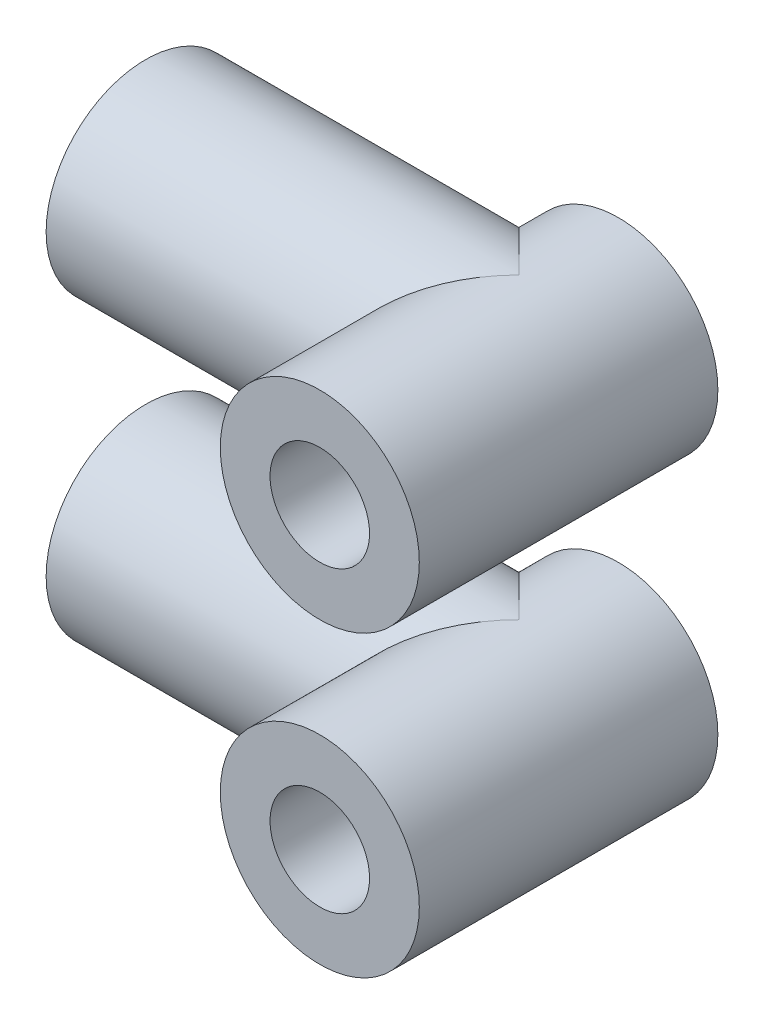
from build123d import *

# Parameters (mm, degrees)
SKETCH1_R           = 4
SKETCH1_R_2         = 2
BOSS_EXTRUDE1_DEPTH = 12
SKETCH2_R           = 4
SKETCH2_R_2         = 2
BOSS_EXTRUDE2_DEPTH = 15
SKETCH3_R           = 2
CUT_EXTRUDE1_DEPTH  = 13.0000001
CUT_EXTRUDE2_REACH  = 21
SKETCH4_R           = 2


with BuildPart() as part:
    # Sketch1 → Boss-Extrude1 (new body)
    with BuildSketch(Plane.XY):
        Circle(SKETCH1_R)
        Circle(SKETCH1_R_2, mode=Mode.SUBTRACT)
    extrude(amount=BOSS_EXTRUDE1_DEPTH)

    # Sketch2 → Boss-Extrude2 (add)
    with BuildSketch(Plane(origin=(0, 0, 0), x_dir=(0, 0, -1), z_dir=(1, 0, 0))):
        with Locations((-4, 0)):
            Circle(SKETCH2_R)
        with Locations((-4, 0)):
            Circle(SKETCH2_R_2, mode=Mode.SUBTRACT)
    extrude(amount=-BOSS_EXTRUDE2_DEPTH)

    # Sketch3 → Cut-Extrude1 (cut, through all)
    with BuildSketch(Plane(origin=(0, 0, 0), x_dir=(-1, 0, 0), z_dir=(0, 0, -1))):
        Circle(SKETCH3_R)
    extrude(amount=-CUT_EXTRUDE1_DEPTH, mode=Mode.SUBTRACT)

    # Sketch4 → Cut-Extrude2 (cut, up to next)
    with BuildSketch(Plane.ZY.offset(15), mode=Mode.PRIVATE) as cut_extrude2_sk1:
        with Locations((4, 0)):
            Circle(SKETCH4_R)
    cut_extrude2_tool1 = extrude(cut_extrude2_sk1.sketch, amount=-CUT_EXTRUDE2_REACH, mode=Mode.PRIVATE) & part.part
    add(cut_extrude2_tool1.solids().sort_by_distance((-15, 0, 4))[0], mode=Mode.SUBTRACT)


with BuildPart() as body_2:
    # Mirror1: mirrored copy
    add(part.part.mirror(Plane.ZX.offset(6)))


solid = Compound([part.part, body_2.part])
